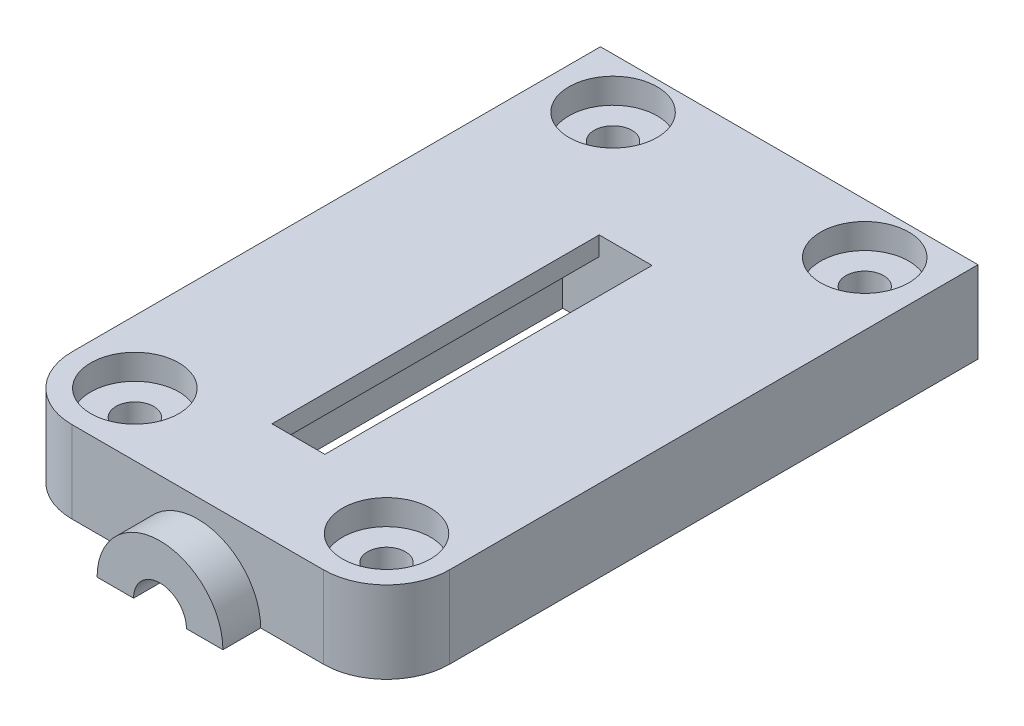
from build123d import *

# Parameters (mm, degrees)
SKETCH1_W           = 30
SKETCH1_H           = 47
BOSS_EXTRUDE1_DEPTH = 6.5
BOSS_EXTRUDE2_DEPTH = 3
SKETCH3_R           = 2.1
CUT_EXTRUDE1_DEPTH  = 50
FILLET1_R           = 5
SKETCH4_R           = 4.1
CUT_EXTRUDE2_DEPTH  = 3.1
SKETCH5_W           = 10
SKETCH5_H           = 26
CUT_EXTRUDE3_DEPTH  = 5
SKETCH9_R           = 4.1
CUT_EXTRUDE4_DEPTH  = 3.1
SKETCH10_R          = 5
CUT_EXTRUDE5_DEPTH  = 6
SKETCH11_R          = 1.5
CUT_EXTRUDE6_DEPTH  = 7.5
SKETCH12_R          = 3.5
CUT_EXTRUDE7_DEPTH  = 2
CUT_EXTRUDE8_DEPTH  = 2.5


with BuildPart() as part:
    # Sketch1 → Boss-Extrude1 (new body)
    with BuildSketch(Plane(origin=(0, 0, 0), x_dir=(1, 0, 0), z_dir=(0, 1, 0))):
        Rectangle(SKETCH1_W, SKETCH1_H)
    extrude(amount=BOSS_EXTRUDE1_DEPTH)

    # Sketch2 → Boss-Extrude2 (add)
    with BuildSketch(Plane.XY.offset(23.5)):
        with BuildLine():
            Line((5, 0), (-5, 0))
            ThreePointArc((-5, 0), (0, 5), (5, 0))
        make_face()
    extrude(amount=BOSS_EXTRUDE2_DEPTH)

    # Sketch3 → Cut-Extrude1 (cut)
    with BuildSketch(Plane.XY.offset(26.5)):
        Circle(SKETCH3_R)
    extrude(amount=-CUT_EXTRUDE1_DEPTH, mode=Mode.SUBTRACT)

    # Fillet1
    fillet1_edges = [part.edges().sort_by_distance(p)[0] for p in [
        (15, 3.25, 23.5),
        (-15, 3.25, 23.5),
    ]]
    fillet(fillet1_edges, radius=FILLET1_R)

    # Sketch4 → Cut-Extrude2 (cut)
    with BuildSketch(Plane.XY.offset(20)):
        Circle(SKETCH4_R)
    extrude(amount=-CUT_EXTRUDE2_DEPTH, mode=Mode.SUBTRACT)

    # Sketch5 → Cut-Extrude3 (cut)
    with BuildSketch(Plane.XZ):
        with Locations((0, 2.5)):
            Rectangle(SKETCH5_W, SKETCH5_H)
    extrude(amount=-CUT_EXTRUDE3_DEPTH, mode=Mode.SUBTRACT)

    # Sketch9 → Cut-Extrude4 (cut)
    with BuildSketch(Plane.XY.offset(-12)):
        Circle(SKETCH9_R)
    extrude(amount=-CUT_EXTRUDE4_DEPTH, mode=Mode.SUBTRACT)

    # Sketch10 → Cut-Extrude5 (cut)
    with BuildSketch(Plane.XY.offset(-16.6)):
        Circle(SKETCH10_R)
    extrude(amount=-CUT_EXTRUDE5_DEPTH, mode=Mode.SUBTRACT)

    # Sketch11 → Cut-Extrude6 (cut, through all)
    with BuildSketch(Plane.XZ):
        with Locations((10, 18.5)):
            Circle(SKETCH11_R)
        with Locations((10, -19.5)):
            Circle(SKETCH11_R)
        with Locations((-10, -19.5)):
            Circle(SKETCH11_R)
        with Locations((-10, 18.5)):
            Circle(SKETCH11_R)
    extrude(amount=-CUT_EXTRUDE6_DEPTH, mode=Mode.SUBTRACT)

    # Sketch12 → Cut-Extrude7 (cut)
    with BuildSketch(Plane(origin=(0, 6.5, 0), x_dir=(1, 0, 0), z_dir=(0, 1, 0))):
        with Locations((-10, 19.5)):
            Circle(SKETCH12_R)
        with Locations((10, 19.5)):
            Circle(SKETCH12_R)
        with Locations((10, -18.5)):
            Circle(SKETCH12_R)
        with Locations((-10, -18.5)):
            Circle(SKETCH12_R)
    extrude(amount=-CUT_EXTRUDE7_DEPTH, mode=Mode.SUBTRACT)

    # Sketch13 → Cut-Extrude8 (cut, through all)
    with BuildSketch(Plane.XZ.offset(-5)):
        Polygon((0, -10.5), (2.1, -10.5), (2.1, 15.5), (-2.1, 15.5), (-2.1, -10.5), align=None)
    extrude(amount=-CUT_EXTRUDE8_DEPTH, mode=Mode.SUBTRACT)


solid = part.part
